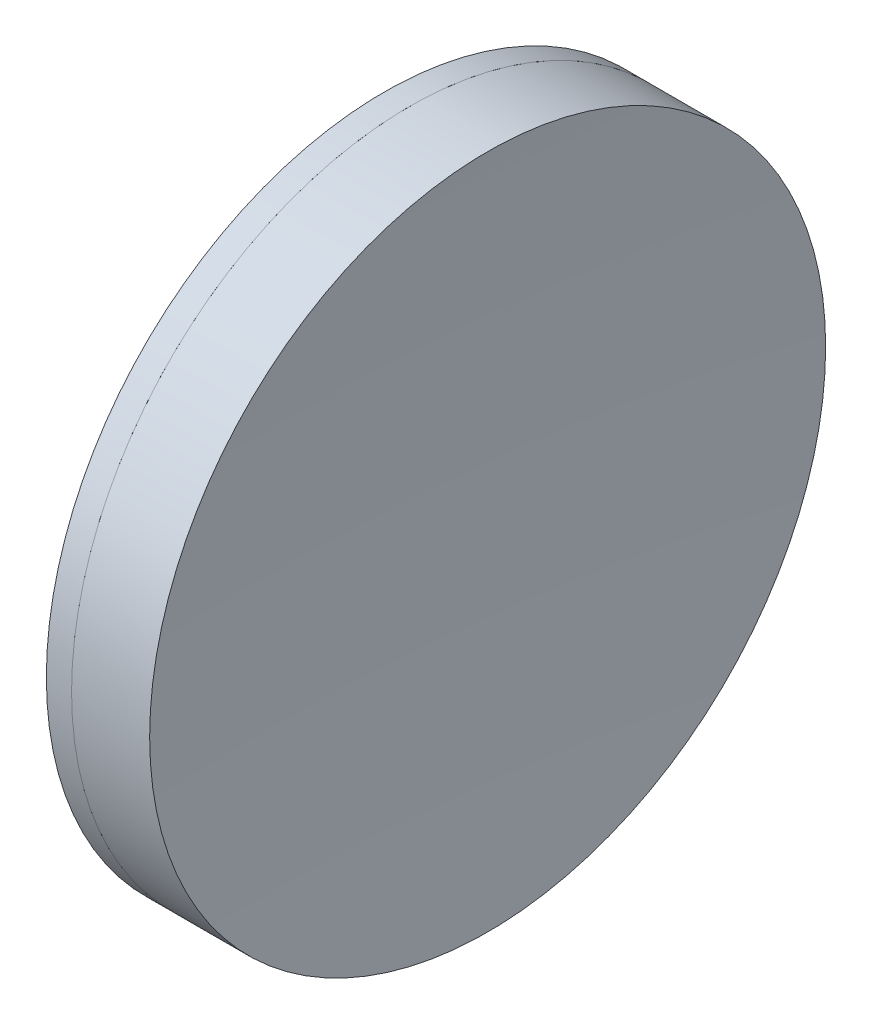
from build123d import *


with BuildPart() as part:
    # 草图1 one side → 旋转1 (revolve)
    with BuildSketch(Plane(origin=(0, 0, 0), x_dir=(1, 0, 0), z_dir=(0, 1, 0)), mode=Mode.PRIVATE) as revolve_1_sk:
        with BuildLine():
            ThreePointArc((201.959891009, 25.4), (200.015233806, 12.76611392), (199.364768961, 0))
            Line((199.364768961, 0), (205.864768961, 0))
            ThreePointArc((205.864768961, 0), (205.361508274, 12.739699007), (203.854862698, 25.4))
            Line((203.854862698, 25.4), (201.959891009, 25.4))
        make_face()
    revolve(revolve_1_sk.sketch.rotate(Axis((-0.816062176, 0, 0), (1, 0, 0)), 180), axis=Axis((-0.816062176, 0, 0), (1, 0, 0)))  # turned: the seam where the file's is


with BuildPart() as body_2:
    # 草图2 one side → 旋转2 (revolve)
    with BuildSketch(Plane(origin=(0, 0, 0), x_dir=(1, 0, 0), z_dir=(0, 1, 0))):
        with BuildLine():
            Line((209.723103497, 25.4), (203.854862698, 25.4))
            ThreePointArc((203.854862698, 25.4), (205.361508274, 12.739699007), (205.864768961, 0))
            Line((205.864768961, 0), (208.864768961, 0))
            ThreePointArc((208.864768961, 0), (209.079413821, 12.707249291), (209.723103497, 25.4))
        make_face()
    revolve(axis=Axis((-0.551919993, 0, 0), (1, 0, 0)))


solid = Compound([part.part, body_2.part])
